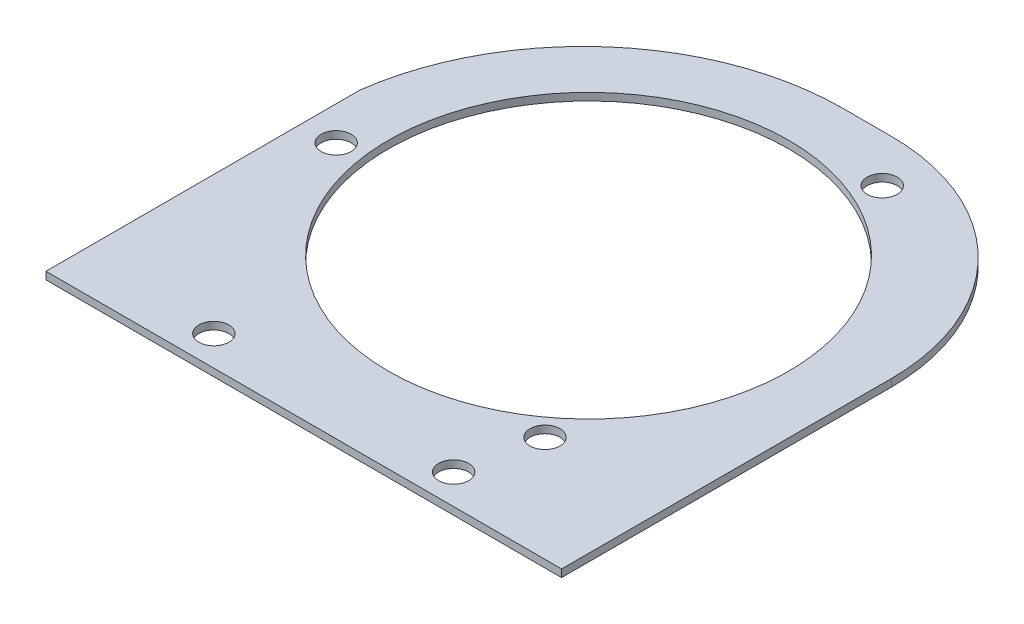
from build123d import *

# Parameters (mm, degrees)
SKETCH1_R           = 84.7725
SKETCH1_R_2         = 6.35
BOSS_EXTRUDE1_DEPTH = 3.175


with BuildPart() as part:
    # Sketch1 → Boss-Extrude1 (new body)
    with BuildSketch(Plane(origin=(0, 0, 0), x_dir=(1, 0, 0), z_dir=(0, 1, 0))):
        with BuildLine():
            Line((16.751670796, 110.565701996), (-3.568329204, 110.565701996))
            ThreePointArc((-3.568329204, 110.565701996), (-76.150812933, 83.28188355), (-112.788329204, 14.942172584))
            Line((-112.788329204, 14.942172584), (-112.788329204, -118.034298004))
            Line((-112.788329204, -118.034298004), (105.651670796, -118.034298004))
            Line((105.651670796, -118.034298004), (105.651670796, 21.665701996))
            ThreePointArc((105.651670796, 21.665701996), (79.613463644, 84.527494844), (16.751670796, 110.565701996))
        make_face()
        with Locations((-3.568329204, 2.615701996)):
            Circle(SKETCH1_R, mode=Mode.SUBTRACT)
        with Locations((-98.436496296, -9.450545062)):
            Circle(SKETCH1_R_2, mode=Mode.SUBTRACT)
        with Locations((-54.368329204, -105.334298004)):
            Circle(SKETCH1_R_2, mode=Mode.SUBTRACT)
        with Locations((47.231670796, -105.334298004)):
            Circle(SKETCH1_R_2, mode=Mode.SUBTRACT)
        with Locations((32.954821104, 90.521109481)):
            Circle(SKETCH1_R_2, mode=Mode.SUBTRACT)
        with Locations((53.837154897, -73.252936495)):
            Circle(SKETCH1_R_2, mode=Mode.SUBTRACT)
    extrude(amount=BOSS_EXTRUDE1_DEPTH)


solid = part.part
